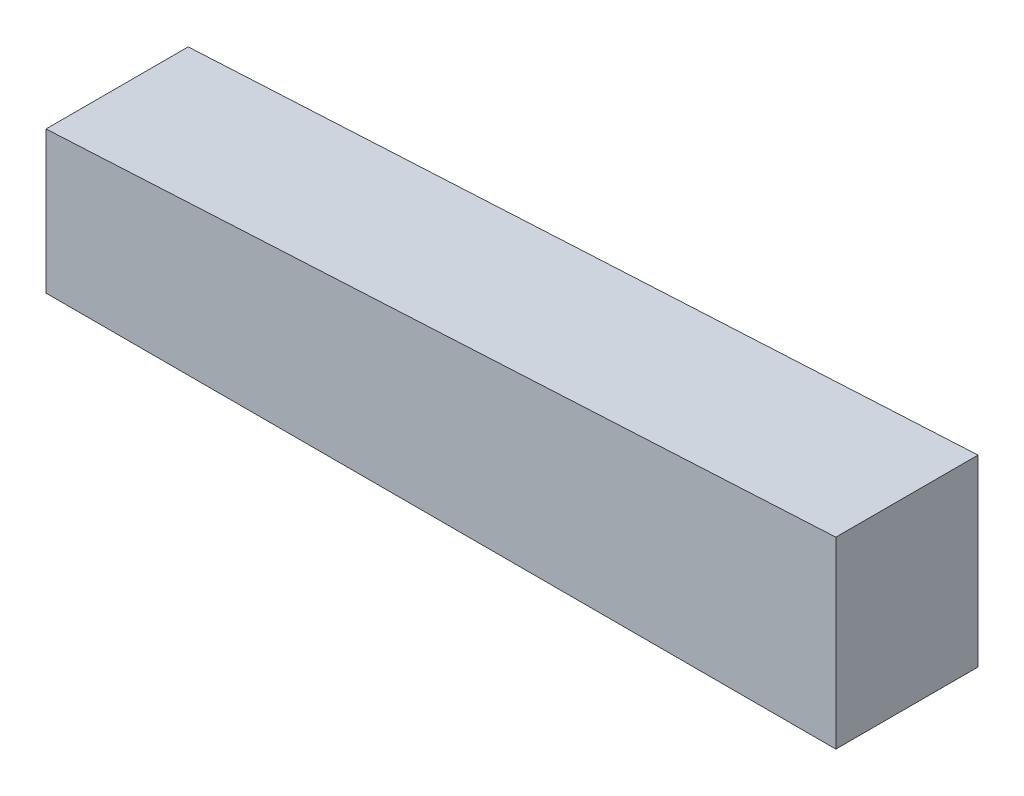
from build123d import *

# Parameters (mm, degrees)
BOSS_EXTRUDE1_DEPTH = 4.5


with BuildPart() as part:
    # Sketch1 → Boss-Extrude1 (new body)
    with BuildSketch(Plane.XY):
        Polygon((0, 0), (25, 0), (25, 5.810194482), (0, 4.5), align=None)
    extrude(amount=BOSS_EXTRUDE1_DEPTH)


solid = part.part
